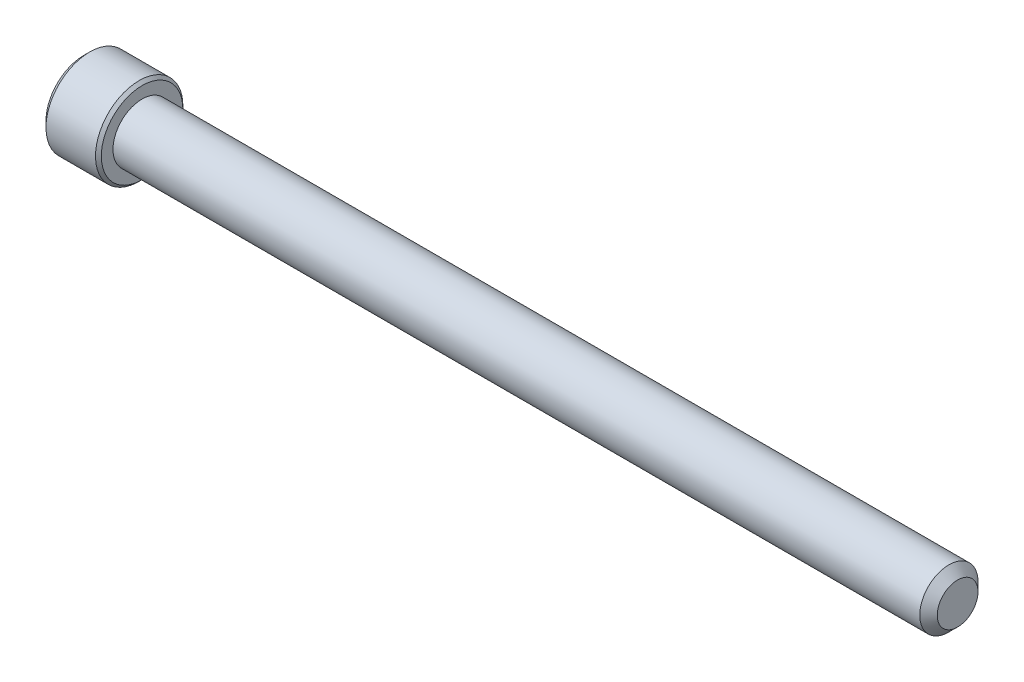
from build123d import *

# Parameters (mm, degrees)
SKETCH2_R           = 3.175
BOSS_EXTRUDE1_DEPTH = 88.9
CHAMFER1_SIZE       = 0.9525
CUT_EXTRUDE1_DEPTH  = 3.048
SKETCH8_R           = 2.749630657
CUT_EXTRUDE2_DEPTH  = 1.27
CUT_EXTRUDE2_TAPER  = 45


with BuildPart() as part:
    # Sketch2 → Boss-Extrude1 (new body)
    with BuildSketch(Plane(origin=(44.45, 0, 0), x_dir=(0, 0, -1), z_dir=(1, 0, 0))):
        Circle(SKETCH2_R)
    extrude(amount=-BOSS_EXTRUDE1_DEPTH)

    # Chamfer1
    chamfer1_edges = [part.edges().sort_by_distance(p)[0] for p in [
        (44.45, 0, 3.175),
    ]]
    chamfer(chamfer1_edges, length=CHAMFER1_SIZE)

    # Sketch6 → Revolve1 (revolve)
    with BuildSketch(Plane.XY):
        Polygon((-50.165, 4.7625), (-50.8, 4.1275), (-50.8, 0), (-44.45, 0), (-44.45, 4.445), (-44.7675, 4.7625), align=None)
    revolve(axis=Axis((-44.45, 0, 0), (-1, 0, 0)))

    # Sketch4 → Cut-Extrude1 (cut)
    with BuildSketch(Plane(origin=(-50.8, 0, 0), x_dir=(0, 0, -1), z_dir=(1, 0, 0))):
        Polygon((0, 2.749630657), (-2.38125, 1.374815329), (-2.38125, -1.374815329), (0, -2.749630657), (2.38125, -1.374815329), (2.38125, 1.374815329), align=None)
    extrude(amount=CUT_EXTRUDE1_DEPTH, mode=Mode.SUBTRACT)

    # Sketch8 → Cut-Extrude2 (cut)
    with BuildSketch(Plane.ZY.offset(50.8)):
        Circle(SKETCH8_R)
    extrude(amount=-CUT_EXTRUDE2_DEPTH, taper=CUT_EXTRUDE2_TAPER, mode=Mode.SUBTRACT)


solid = part.part
